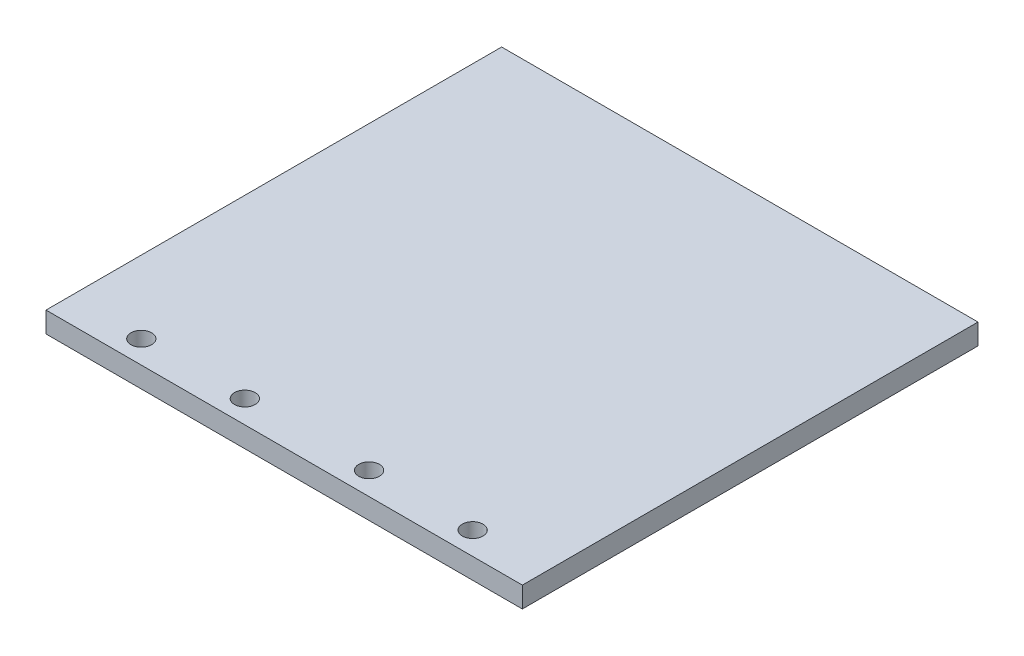
from build123d import *

# Parameters (mm, degrees)
SKETCH2_W           = 115
SKETCH2_H           = 110
BOSS_EXTRUDE1_DEPTH = 5
CUT_EXTRUDE1_REACH  = 7
SKETCH3_R           = 2.5


with BuildPart() as part:
    # Sketch2 → Boss-Extrude1 (new body)
    with BuildSketch(Plane(origin=(0, 0, 0), x_dir=(1, 0, 0), z_dir=(0, 1, 0))):
        Rectangle(SKETCH2_W, SKETCH2_H)
    extrude(amount=BOSS_EXTRUDE1_DEPTH)

    # Sketch3 → Cut-Extrude1 (cut, up to next)
    with BuildSketch(Plane.XZ, mode=Mode.PRIVATE) as cut_extrude1_sk1:
        with Locations((-40, 49.5)):
            Circle(SKETCH3_R)
    cut_extrude1_tool1 = extrude(cut_extrude1_sk1.sketch, amount=-CUT_EXTRUDE1_REACH, mode=Mode.PRIVATE) & part.part
    add(cut_extrude1_tool1.solids().sort_by_distance((-40, 0, 49.5))[0], mode=Mode.SUBTRACT)
    # Sketch3 → Cut-Extrude1 (cut, up to next)
    with BuildSketch(Plane.XZ, mode=Mode.PRIVATE) as cut_extrude1_sk2:
        with Locations((-15, 49.5)):
            Circle(SKETCH3_R)
    cut_extrude1_tool2 = extrude(cut_extrude1_sk2.sketch, amount=-CUT_EXTRUDE1_REACH, mode=Mode.PRIVATE) & part.part
    add(cut_extrude1_tool2.solids().sort_by_distance((-15, 0, 49.5))[0], mode=Mode.SUBTRACT)
    # Sketch3 → Cut-Extrude1 (cut, up to next)
    with BuildSketch(Plane.XZ, mode=Mode.PRIVATE) as cut_extrude1_sk3:
        with Locations((40, 49.5)):
            Circle(SKETCH3_R)
    cut_extrude1_tool3 = extrude(cut_extrude1_sk3.sketch, amount=-CUT_EXTRUDE1_REACH, mode=Mode.PRIVATE) & part.part
    add(cut_extrude1_tool3.solids().sort_by_distance((40, 0, 49.5))[0], mode=Mode.SUBTRACT)
    # Sketch3 → Cut-Extrude1 (cut, up to next)
    with BuildSketch(Plane.XZ, mode=Mode.PRIVATE) as cut_extrude1_sk4:
        with Locations((15, 49.5)):
            Circle(SKETCH3_R)
    cut_extrude1_tool4 = extrude(cut_extrude1_sk4.sketch, amount=-CUT_EXTRUDE1_REACH, mode=Mode.PRIVATE) & part.part
    add(cut_extrude1_tool4.solids().sort_by_distance((15, 0, 49.5))[0], mode=Mode.SUBTRACT)


solid = part.part
